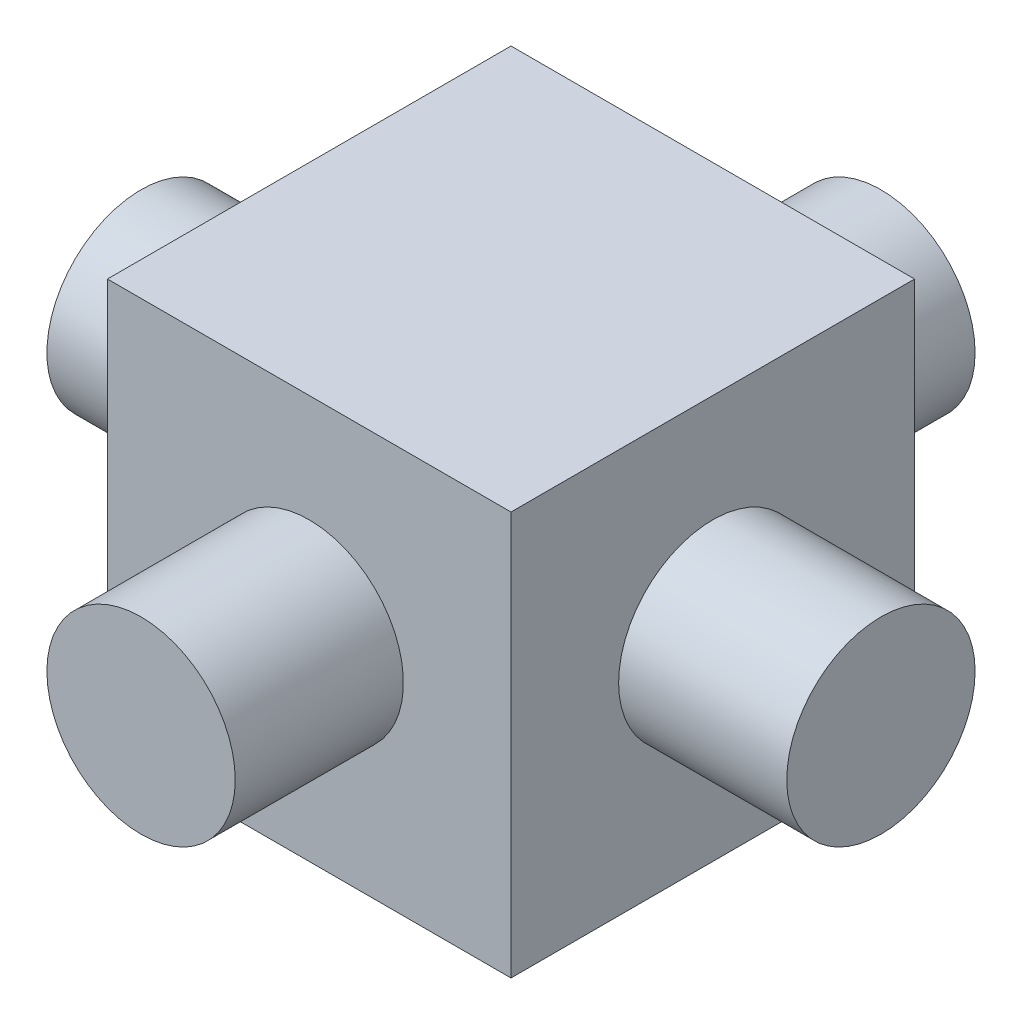
from build123d import *

# Parameters (mm, degrees)
SKETCH_1_W      = 6
SKETCH_1_H      = 6
EXTRUDE_1_DEPTH = 6
SKETCH_2_R      = 1.4
EXTRUDE_2_DEPTH = 5.5
SKETCH_3_R      = 1.4
EXTRUDE_3_DEPTH = 5.5


with BuildPart() as part:
    # 草图1 → 凸台-拉伸1 (new body)
    with BuildSketch(Plane(origin=(0, 0, 0), x_dir=(1, 0, 0), z_dir=(0, 1, 0))):
        Rectangle(SKETCH_1_W, SKETCH_1_H)
    extrude(amount=EXTRUDE_1_DEPTH)

    # 草图2 → 凸台-拉伸2 (add, symmetric)
    with BuildSketch(Plane.XY):
        with Locations((0, 3)):
            Circle(SKETCH_2_R)
    extrude(amount=EXTRUDE_2_DEPTH, both=True)

    # 草图3 → 凸台-拉伸3 (add, symmetric)
    with BuildSketch(Plane(origin=(0, 0, 0), x_dir=(0, 0, -1), z_dir=(1, 0, 0))):
        with Locations((0, 3)):
            Circle(SKETCH_3_R)
    extrude(amount=EXTRUDE_3_DEPTH, both=True)


solid = part.part
